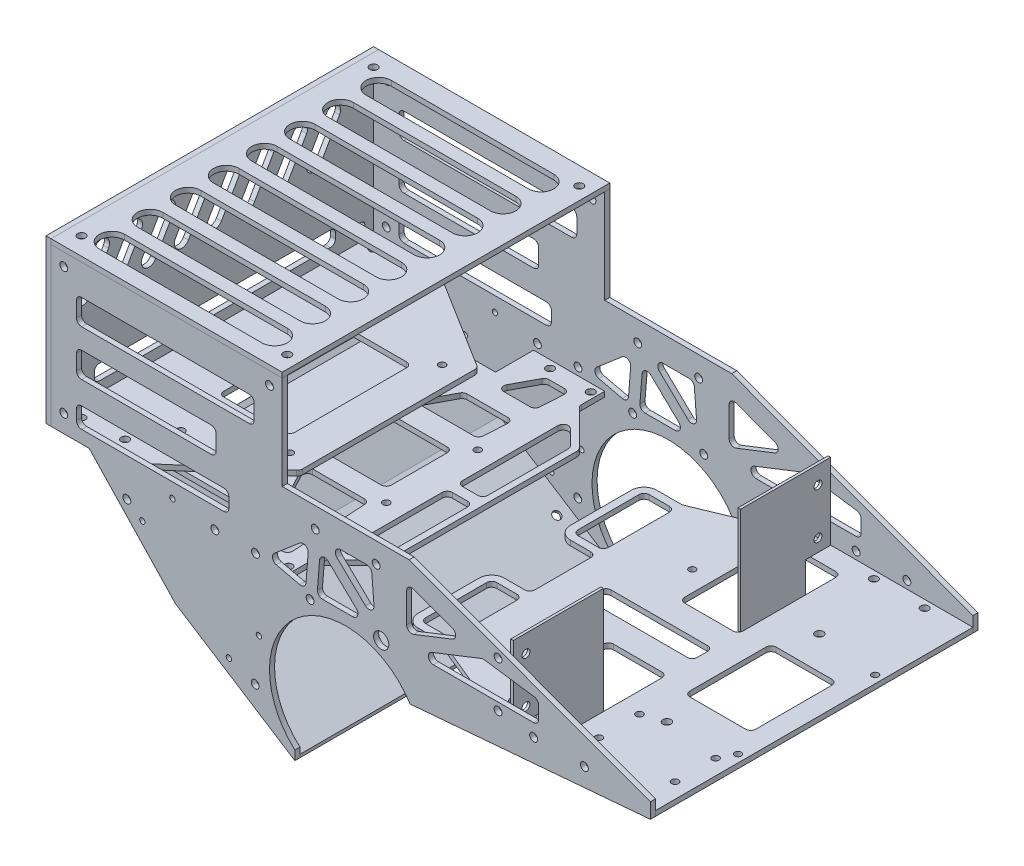
from build123d import *
from build123d.topology import SkipClean

# Parameters (mm, degrees)
SKETCH_1_R                = 1.55
EXTRUDE_1_DEPTH           = 2
SKETCH_2_R                = 1.3
SKETCH_2_R_2              = 1.35
SKETCH_2_R_3              = 1.6
SKETCH_2_W                = 42
SKETCH_2_H                = 8
EXTRUDE_2_DEPTH           = 2
EXTRUDE_START             = -125
SKETCH_1_2_R              = 1.55
EXTRUDE_3_DEPTH           = 2
EXTRUDE_START_2           = -25
SKETCH_16_R               = 1.35
SKETCH_16_R_2             = 1.55
SKETCH_16_W               = 28
SKETCH_16_H               = 48
EXTRUDE_13_DEPTH          = 2
EXTRUDE_START_3           = -10
SKETCH_17_R               = 1.35
SKETCH_17_R_2             = 1.55
SKETCH_17_W               = 26
SKETCH_17_H               = 26
EXTRUDE_14_DEPTH          = 2
SKETCH_47_W               = 10
SKETCH_47_H               = 4
EXTRUDE_27_DEPTH          = 2
EXTRUDE_15_DEPTH          = 2
EXTRUDE_16_DEPTH          = 125
EXTRUDE_16_2_DEPTH        = 125
SKETCH_38_R               = 1.55
CUT_EXTRUDE_12_DEPTH      = 2
SKETCH_31_R               = 1.55
CUT_EXTRUDE_7_DEPTH       = 2
SKETCH_62_R               = 1.55
CUT_EXTRUDE_28_DEPTH      = 228.682265925
SKETCH_39_R               = 1.55
CUT_EXTRUDE_13_DEPTH      = 204.580450928
CUT_EXTRUDE_15_DEPTH      = 203.31905496
CUT_EXTRUDE_15_DEPTH_BACK = 203.31905496
SKETCH_48_W               = 23
SKETCH_48_H               = 40.5
SKETCH_48_W_2             = 26
SKETCH_48_H_2             = 34
CUT_EXTRUDE_19_DEPTH      = 10
FILLET_3_R                = 2
FILLET_6_R                = 2
EXTRUDE_START_4           = -127
EXTRUDE_29_DEPTH          = 2
SKETCH_51_W               = 91
SKETCH_51_H               = 129
EXTRUDE_30_DEPTH          = 2
SKETCH_52_W               = 129
SKETCH_52_H               = 64
EXTRUDE_31_DEPTH          = 2
SKETCH_53_R               = 1.05
SKETCH_53_R_2             = 1.55
CUT_EXTRUDE_20_DEPTH      = 204.334699449
CUT_EXTRUDE_20_DEPTH_BACK = 204.334699449
FILLET_7_R                = 2
SKETCH_55_R               = 1.55
SKETCH_55_W               = 70
SKETCH_55_H               = 10
SKETCH_55_W_2             = 55
SKETCH_55_W_3             = 60
SKETCH_55_H_2             = 8
CUT_EXTRUDE_21_DEPTH      = 205.58983357
SKETCH_56_R               = 1.55
CUT_EXTRUDE_22_DEPTH      = 10
SKETCH_57_R               = 1.55
SKETCH_57_W               = 95
SKETCH_57_H               = 6
CUT_EXTRUDE_23_DEPTH      = 10
EXTRUDE_START_5           = 63
SKETCH_58_W               = 125
SKETCH_58_H               = 42
EXTRUDE_32_DEPTH          = 1
SKETCH_59_R               = 1.55
SKETCH_59_W               = 10
SKETCH_59_H               = 12
SKETCH_59_W_2             = 54
SKETCH_59_H_2             = 50
CUT_EXTRUDE_24_DEPTH      = 2
FILLET_8_R                = 2
FILLET_9_R                = 2
FILLET_10_R               = 2
SKETCH_60_R               = 1.55
CUT_EXTRUDE_26_DEPTH      = 204.334699449
FILLET_11_R               = 2
FILLET_12_R               = 2
SKETCH_61_R               = 3
CUT_EXTRUDE_27_DEPTH      = 2
SKETCH_64_R               = 1.55
CUT_EXTRUDE_29_DEPTH      = 10
SKETCH_65_R               = 1.55
CUT_EXTRUDE_30_DEPTH      = 10


with BuildPart() as part:
    # Sketch 1 → Extrude 1 (new body)
    with BuildSketch(Plane.XY):
        with BuildLine():
            Line((-45, 65), (25, 65))
            Line((25, 65), (120, 30))
            Line((120, 30), (120, 24))
            Line((120, 24), (25.377155081, 16))
            ThreePointArc((25.377155081, 16), (5.441103222, 29.502447284), (-18, 24))
            Line((-18, 24), (-45, 24))
            Line((-45, 24), (-45, 65))
        make_face()
        with Locations((-12, 57)):
            Circle(SKETCH_1_R, mode=Mode.SUBTRACT)
        with Locations((12, 57)):
            Circle(SKETCH_1_R, mode=Mode.SUBTRACT)
        with Locations((60, 49)):
            Circle(SKETCH_1_R, mode=Mode.SUBTRACT)
        with Locations((14, 32)):
            Circle(SKETCH_1_R, mode=Mode.SUBTRACT)
        with Locations((-14, 32)):
            Circle(SKETCH_1_R, mode=Mode.SUBTRACT)
        with Locations((60, 31)):
            Circle(SKETCH_1_R, mode=Mode.SUBTRACT)
    extrude(amount=EXTRUDE_1_DEPTH)


with BuildPart() as body_2:
    # Sketch 2 → Extrude 2 (new body)
    with BuildSketch(Plane(origin=(0, 24, 0), x_dir=(1, 0, 0), z_dir=(0, 1, 0))):
        with BuildLine():
            Line((120, 0), (120, 125))
            Line((120, 125), (21, 125))
            Line((21, 125), (21, 109.5))
            Line((21, 109.5), (11, 109.5))
            ThreePointArc((11, 109.5), (7.464466094, 108.035533906), (6, 104.5))
            Line((6, 104.5), (6, 80.5))
            ThreePointArc((6, 80.5), (7.464466094, 76.964466094), (11, 75.5))
            Line((11, 75.5), (21, 75.5))
            Line((21, 75.5), (21, 49.5))
            Line((21, 49.5), (11, 49.5))
            ThreePointArc((11, 49.5), (7.464466094, 48.035533906), (6, 44.5))
            Line((6, 44.5), (6, 20.5))
            ThreePointArc((6, 20.5), (7.464466094, 16.964466094), (11, 15.5))
            Line((11, 15.5), (21, 15.5))
            Line((21, 15.5), (21, 0))
            Line((21, 0), (120, 0))
        make_face()
        with Locations(Location((117, 89.5, 0), (0, 0, 180))):
            Circle(SKETCH_2_R, mode=Mode.SUBTRACT)
        with Locations(Location((117, 35.5, 0), (0, 0, 180))):
            Circle(SKETCH_2_R, mode=Mode.SUBTRACT)
        with Locations(Location((45, 35.5, 0), (0, 0, 180))):
            Circle(SKETCH_2_R, mode=Mode.SUBTRACT)
        with Locations(Location((45, 89.5, 0), (0, 0, 180))):
            Circle(SKETCH_2_R, mode=Mode.SUBTRACT)
        with Locations(Location((84, 13.7, 0), (0, 0, 180))):
            Circle(SKETCH_2_R_2, mode=Mode.SUBTRACT)
        with Locations(Location((84, 29.7, 0), (0, 0, 180))):
            Circle(SKETCH_2_R_2, mode=Mode.SUBTRACT)
        with Locations(Location((114, 13.7, 0), (0, 0, 180))):
            Circle(SKETCH_2_R_2, mode=Mode.SUBTRACT)
        with Locations(Location((114, 29.7, 0), (0, 0, 180))):
            Circle(SKETCH_2_R_2, mode=Mode.SUBTRACT)
        with Locations(Location((92, 92.5, 0), (0, 0, 180))):
            Circle(SKETCH_2_R_3, mode=Mode.SUBTRACT)
        with Locations(Location((92, 32.5, 0), (0, 0, 180))):
            Circle(SKETCH_2_R_3, mode=Mode.SUBTRACT)
        with Locations(Location((60, 5, 0), (0, 0, 180))):
            Circle(SKETCH_2_R_3, mode=Mode.SUBTRACT)
        with Locations((60, 120)):
            Circle(SKETCH_2_R_3, mode=Mode.SUBTRACT)
        with BuildLine():
            Line((21, 106.5), (11, 106.5))
            ThreePointArc((11, 106.5), (9.585786438, 105.914213562), (9, 104.5))
            Line((9, 104.5), (9, 80.5))
            ThreePointArc((9, 80.5), (9.585786438, 79.085786438), (11, 78.5))
            Line((11, 78.5), (21, 78.5))
            Line((21, 78.5), (21, 106.5))
        make_face(mode=Mode.SUBTRACT)
        with BuildLine():
            Line((21, 46.5), (21, 18.5))
            Line((21, 18.5), (11, 18.5))
            ThreePointArc((11, 18.5), (9.585786438, 19.085786438), (9, 20.5))
            Line((9, 20.5), (9, 44.5))
            ThreePointArc((9, 44.5), (9.585786438, 45.914213562), (11, 46.5))
            Line((11, 46.5), (21, 46.5))
        make_face(mode=Mode.SUBTRACT)
        with Locations((55, 62.5)):
            Rectangle(SKETCH_2_W, SKETCH_2_H, mode=Mode.SUBTRACT)
    extrude(amount=EXTRUDE_2_DEPTH)

    # Sketch 38 → Cut-Extrude 12 (cut)
    with BuildSketch(Plane.XZ.offset(-24)):
        with Locations((104, -3)):
            Circle(SKETCH_38_R)
        with Locations((84, -3)):
            Circle(SKETCH_38_R)
        with Locations((84, -122)):
            Circle(SKETCH_38_R)
        with Locations((104, -122)):
            Circle(SKETCH_38_R)
    extrude(amount=-CUT_EXTRUDE_12_DEPTH, mode=Mode.SUBTRACT)

    # Sketch 48 → Cut-Extrude 19 (cut)
    with BuildSketch(Plane.XZ.offset(-24)):
        with Locations((64.5, -96.75)):
            Rectangle(SKETCH_48_W, SKETCH_48_H)
        with Locations((64.5, -28.25)):
            Rectangle(SKETCH_48_W, SKETCH_48_H)
        Polygon((21, -125), (21, -109.5), (58.45, -125), align=None)
        Polygon((21, -15.5), (21, 0), (58.45, 0), align=None)
        with Locations((99, -62.5)):
            Rectangle(SKETCH_48_W_2, SKETCH_48_H_2)
    extrude(amount=-CUT_EXTRUDE_19_DEPTH, mode=Mode.SUBTRACT)

    # Fillet 3
    fillet_3_edges = [body_2.edges().sort_by_distance(p)[0] for p in [
        (21, 25, -18.5),
        (21, 25, -46.5),
        (53, 25, -48.5),
        (53, 25, -8),
        (76, 25, -8),
        (76, 25, -48.5),
        (86, 25, -79.5),
        (86, 25, -45.5),
        (112, 25, -45.5),
        (112, 25, -79.5),
        (53, 25, -117),
        (53, 25, -76.5),
        (76, 25, -76.5),
        (76, 25, -117),
        (21, 25, -15.5),
        (21, 25, -49.5),
        (21, 25, -75.5),
        (21, 25, -109.5),
        (21, 25, -78.5),
        (21, 25, -106.5),
        (34, 25, -66.5),
        (34, 25, -58.5),
        (76, 25, -58.5),
        (76, 25, -66.5),
    ]]
    fillet(fillet_3_edges, radius=FILLET_3_R)


with BuildPart() as body_3:
    # Sketch 1_2 → Extrude 3 (new body)
    with BuildSketch(Plane.XY.offset(EXTRUDE_START)):
        with BuildLine():
            Line((-45, 65), (25, 65))
            Line((25, 65), (120, 30))
            Line((120, 30), (120, 24))
            Line((120, 24), (25.377155081, 16))
            ThreePointArc((25.377155081, 16), (5.441103222, 29.502447284), (-18, 24))
            Line((-18, 24), (-45, 24))
            Line((-45, 24), (-45, 65))
        make_face()
        with Locations((-12, 57)):
            Circle(SKETCH_1_2_R, mode=Mode.SUBTRACT)
        with Locations((12, 57)):
            Circle(SKETCH_1_2_R, mode=Mode.SUBTRACT)
        with Locations((60, 49)):
            Circle(SKETCH_1_2_R, mode=Mode.SUBTRACT)
        with Locations((14, 32)):
            Circle(SKETCH_1_2_R, mode=Mode.SUBTRACT)
        with Locations((-14, 32)):
            Circle(SKETCH_1_2_R, mode=Mode.SUBTRACT)
        with Locations((60, 31)):
            Circle(SKETCH_1_2_R, mode=Mode.SUBTRACT)
    extrude(amount=-EXTRUDE_3_DEPTH)

    # Sketch 18 → Extrude 15 (add)
    with SkipClean():  # the faces are left unmerged after this step: merging them gives an invalid solid
        with BuildSketch(Plane(origin=(0, 0, -127), x_dir=(-1, 0, 0), z_dir=(0, 0, -1))):
            with BuildLine():
                Line((101, 40), (67, 4))
                Line((67, 4), (20, -26))
                Line((20, -26), (20, -22.360679775))
                ThreePointArc((20, -22.360679775), (29.972123003, 1.292997564), (18, 24))
                Line((18, 24), (45, 24))
                Line((45, 24), (45, 40))
                Line((45, 40), (45, 65))
                Line((45, 65), (25, 65))
                Line((25, 65), (25, 102))
                Line((25, 102), (116, 102))
                Line((116, 102), (116, 40))
                Line((116, 40), (101, 40))
            make_face()
        extrude(amount=-EXTRUDE_15_DEPTH)

    # Sketch 31 → Cut-Extrude 7 (cut)
    with SkipClean():  # the faces are left unmerged after this step: merging them gives an invalid solid
        with BuildSketch(Plane(origin=(0, 0, -127), x_dir=(-1, 0, 0), z_dir=(0, 0, -1))):
            with Locations((35.62096265, -7.724729116)):
                Circle(SKETCH_31_R)
            with Locations((86.148733825, 30.100738593)):
                Circle(SKETCH_31_R)
        extrude(amount=-CUT_EXTRUDE_7_DEPTH, mode=Mode.SUBTRACT)


with BuildPart() as body_4:
    # Sketch 16 → Extrude 13 (new body)
    with BuildSketch(Plane(origin=(0, 65, 0), x_dir=(1, 0, 0), z_dir=(0, 1, 0)).offset(EXTRUDE_START_2)):
        Polygon((-50, 30), (-85, 0), (-116, 0), (-116, 125), (-90, 125), (-50, 100), align=None)
        with Locations(Location((-98, 34, 0), (0, 0, 270))):
            Circle(SKETCH_16_R, mode=Mode.SUBTRACT)
        with Locations(Location((-58, 34, 0), (0, 0, 270))):
            Circle(SKETCH_16_R, mode=Mode.SUBTRACT)
        with Locations(Location((-58, 94, 0), (0, 0, 270))):
            Circle(SKETCH_16_R, mode=Mode.SUBTRACT)
        with Locations(Location((-98, 94, 0), (0, 0, 270))):
            Circle(SKETCH_16_R, mode=Mode.SUBTRACT)
        with Locations(Location((-111, 120, 0), (0, 0, 270))):
            Circle(SKETCH_16_R_2, mode=Mode.SUBTRACT)
        with Locations(Location((-111, 5, 0), (0, 0, 270))):
            Circle(SKETCH_16_R_2, mode=Mode.SUBTRACT)
        with Locations((-78, 64)):
            Rectangle(SKETCH_16_W, SKETCH_16_H, mode=Mode.SUBTRACT)
    extrude(amount=EXTRUDE_13_DEPTH)


with BuildPart() as body_5:
    # Sketch 17 → Extrude 14 (new body)
    with BuildSketch(Plane.XZ.offset(-24).offset(EXTRUDE_START_3)):
        Polygon((-25, -125), (-53, -125), (-53, -110), (-90, -110), (-90, -15), (-53, -15), (-53, 0), (-25, 0), align=None)
        with Locations((-66, -80)):
            Circle(SKETCH_17_R, mode=Mode.SUBTRACT)
        with Locations((-30, -80)):
            Circle(SKETCH_17_R, mode=Mode.SUBTRACT)
        with Locations((-30, -44)):
            Circle(SKETCH_17_R, mode=Mode.SUBTRACT)
        with Locations((-66, -44)):
            Circle(SKETCH_17_R, mode=Mode.SUBTRACT)
        with Locations((-27.5, -3)):
            Circle(SKETCH_17_R_2, mode=Mode.SUBTRACT)
        with Locations((-43.5, -3)):
            Circle(SKETCH_17_R_2, mode=Mode.SUBTRACT)
        with Locations(Location((-27.5, -122, 0), (0, 0, 180))):
            Circle(SKETCH_17_R_2, mode=Mode.SUBTRACT)
        with Locations(Location((-43.5, -122, 0), (0, 0, 180))):
            Circle(SKETCH_17_R_2, mode=Mode.SUBTRACT)
        with Locations((-48, -62)):
            Rectangle(SKETCH_17_W, SKETCH_17_H, mode=Mode.SUBTRACT)
        Polygon((-41.105034236, -118), (-48.06931995, -105), (-32.518984664, -105), (-31.74517514, -118), align=None, mode=Mode.SUBTRACT)
        Polygon((-52.355034236, -97), (-59.31931995, -84), (-33.768984664, -84), (-32.99517514, -97), align=None, mode=Mode.SUBTRACT)
        Polygon((-52.355034236, -28), (-32.99517514, -28), (-33.768984664, -41), (-59.31931995, -41), align=None, mode=Mode.SUBTRACT)
        Polygon((-41.105034236, -7), (-31.74517514, -7), (-32.518984664, -20), (-48.06931995, -20), align=None, mode=Mode.SUBTRACT)
    extrude(amount=EXTRUDE_14_DEPTH)

    # Sketch 47 → Extrude 27 (add)
    with BuildSketch(Plane(origin=(0, 34, 0), x_dir=(1, 0, 0), z_dir=(0, 1, 0))):
        Polygon((-10, 100), (-25, 115), (-25, 10), (-10, 25), align=None)
        Polygon((-22.5, 64.5), (-22.5, 108.964466094), (-12.5, 98.964466094), (-12.5, 64.5), (-12.5, 60.5), (-12.5, 26.035533906), (-22.5, 16.035533906), (-22.5, 60.5), align=None, mode=Mode.SUBTRACT)
        with Locations((-17.5, 62.5)):
            Rectangle(SKETCH_47_W, SKETCH_47_H)
    extrude(amount=-EXTRUDE_27_DEPTH)

    # Fillet 6
    fillet_6_edges = [body_5.edges().sort_by_distance(p)[0] for p in [
        (-25, 33, -10),
        (-25, 33, -115),
        (-12.5, 33, -64.5),
        (-12.5, 33, -98.964466094),
        (-22.5, 33, -108.964466094),
        (-12.5, 33, -60.5),
        (-22.5, 33, -60.5),
        (-22.5, 33, -16.035533906),
        (-22.5, 33, -64.5),
        (-12.5, 33, -26.035533906),
    ]]
    fillet(fillet_6_edges, radius=FILLET_6_R)

    # Fillet 7
    fillet_7_edges = [body_5.edges().sort_by_distance(p)[0] for p in [
        (-10, 33, -25),
        (-10, 33, -100),
    ]]
    fillet(fillet_7_edges, radius=FILLET_7_R)


with BuildPart() as body_6:
    # Sketch 19 → Extrude 16 (new body)
    with BuildSketch(Plane.XY.offset(-125)):
        Polygon((-66.895855681, 3.933524903), (-20, -26), (-20, -24.813650906), (-66.357820228, 4.776447112), align=None)
    extrude(amount=EXTRUDE_16_DEPTH)

    # Sketch 62 → Cut-Extrude 28 (cut, through all)
    with BuildSketch(Plane(origin=(-17.581215825, -27.543904793, 0), x_dir=(0.8429222095775879, -0.5380354529218656, 0), z_dir=(-0.5380354529218656, -0.8429222095775879, 0))):
        with Locations((-25.869522416, -120)):
            Circle(SKETCH_62_R)
        with Locations((-25.869522416, -5)):
            Circle(SKETCH_62_R)
    extrude(amount=-CUT_EXTRUDE_28_DEPTH, mode=Mode.SUBTRACT)

    # Sketch 65 → Cut-Extrude 30 (cut)
    with BuildSketch(Plane(origin=(-17.581215825, -27.543904793, 0), x_dir=(0.8429222095775879, -0.5380354529218656, 0), z_dir=(-0.5380354529218656, -0.8429222095775879, 0))):
        with Locations((-53.504378335, -72.5)):
            Circle(SKETCH_65_R)
        with Locations((-53.504378335, -52.5)):
            Circle(SKETCH_65_R)
    extrude(amount=-CUT_EXTRUDE_30_DEPTH, mode=Mode.SUBTRACT)


with BuildPart() as body_7:
    # Sketch 19 → Extrude 16 2 (new body)
    with BuildSketch(Plane.XY.offset(-125)):
        Polygon((-67.08483338, 4.089823579), (-66.357820228, 4.776447112), (-93.406751518, 33.416492007), (-94.13376467, 32.729868475), align=None)
    extrude(amount=EXTRUDE_16_2_DEPTH)

    # Sketch 64 → Cut-Extrude 29 (cut)
    with BuildSketch(Plane(origin=(-33.415986949, -31.55954323, 0), x_dir=(0, 0, 1), z_dir=(-0.7270131525498174, -0.6866235329637167, 0))):
        with Locations(Location((-72.5, 54.035380838, 0), (0, 0, 270))):
            Circle(SKETCH_64_R)
        with Locations(Location((-52.5, 54.035380838, 0), (0, 0, 270))):
            Circle(SKETCH_64_R)
        with Locations(Location((-120, 81.035380838, 0), (0, 0, 270))):
            Circle(SKETCH_64_R)
        with Locations(Location((-5, 81.035380838, 0), (0, 0, 270))):
            Circle(SKETCH_64_R)
    extrude(amount=-CUT_EXTRUDE_29_DEPTH, mode=Mode.SUBTRACT)


with BuildPart() as cut_extrude_13_tool:
    # Sketch 39 → Cut-Extrude 13 (new, through all)
    with SkipClean():  # the faces are left unmerged after this step: merging them gives an invalid solid
        with BuildSketch(Plane(origin=(0, 0, -127), x_dir=(-1, 0, 0), z_dir=(0, 0, -1))):
            with Locations((-74, 29)):
                Circle(SKETCH_39_R)
            with Locations((-94, 29)):
                Circle(SKETCH_39_R)
        extrude(amount=-CUT_EXTRUDE_13_DEPTH)


with BuildPart() as part_1:
    with SkipClean():  # the faces are left unmerged after this step: merging them gives an invalid solid
        add(part.part)

        # Cut-Extrude 13: cut by cut_extrude_13_tool
        add(cut_extrude_13_tool.part, mode=Mode.SUBTRACT)


with BuildPart() as body_3_1:
    with SkipClean():  # the faces are left unmerged after this step: merging them gives an invalid solid
        add(body_3.part)

        # Cut-Extrude 13: cut by cut_extrude_13_tool
        add(cut_extrude_13_tool.part, mode=Mode.SUBTRACT)


with BuildPart() as cut_extrude_15_tool:
    # Sketch 41 → Cut-Extrude 15 (new, two sides)
    with SkipClean():  # the faces are left unmerged after this step: merging them gives an invalid solid
        with BuildSketch(Plane(origin=(0, 0, 0), x_dir=(-1, 0, 0), z_dir=(0, 0, -1))) as cut_extrude_15_sk:
            Polygon((-24, 56.84275506), (-24, 39.372271948), (-46.94445184, 48.389535961), align=None)
            Polygon((-24, 34), (-76, 34), (-76, 37.684860324), (-76, 42.684860324), (-54, 45.790123482), align=None)
        extrude(amount=CUT_EXTRUDE_15_DEPTH)
        extrude(cut_extrude_15_sk.sketch, amount=-CUT_EXTRUDE_15_DEPTH_BACK)


with BuildPart() as part_2:
    with SkipClean():  # the faces are left unmerged after this step: merging them gives an invalid solid
        add(part_1.part)

        # Cut-Extrude 15: cut by cut_extrude_15_tool
        add(cut_extrude_15_tool.part, mode=Mode.SUBTRACT)

    # Sketch 18_2 → Extrude 29 (add)
    with BuildSketch(Plane(origin=(0, 0, -127), x_dir=(-1, 0, 0), z_dir=(0, 0, -1)).offset(EXTRUDE_START_4)):
        with BuildLine():
            Line((101, 40), (67, 4))
            Line((67, 4), (20, -26))
            Line((20, -26), (20, -22.360679775))
            ThreePointArc((20, -22.360679775), (29.972123003, 1.292997564), (18, 24))
            Line((18, 24), (45, 24))
            Line((45, 24), (45, 40))
            Line((45, 40), (45, 65))
            Line((45, 65), (25, 65))
            Line((25, 65), (25, 102))
            Line((25, 102), (116, 102))
            Line((116, 102), (116, 40))
            Line((116, 40), (101, 40))
        make_face()
    extrude(amount=-EXTRUDE_29_DEPTH)


with BuildPart() as body_3_2:
    with SkipClean():  # the faces are left unmerged after this step: merging them gives an invalid solid
        add(body_3_1.part)

        # Cut-Extrude 15: cut by cut_extrude_15_tool
        add(cut_extrude_15_tool.part, mode=Mode.SUBTRACT)


with BuildPart() as body_8:
    # Sketch 51 → Extrude 30 (new body)
    with BuildSketch(Plane(origin=(0, 102, 0), x_dir=(1, 0, 0), z_dir=(0, 1, 0))):
        with Locations((-70.5, 62.5)):
            Rectangle(SKETCH_51_W, SKETCH_51_H)
    extrude(amount=EXTRUDE_30_DEPTH)

    # Sketch 56 → Cut-Extrude 22 (cut)
    with BuildSketch(Plane(origin=(0, 104, 0), x_dir=(1, 0, 0), z_dir=(0, 1, 0))):
        with Locations(Location((-30, 5, 0), (0, 0, 270))):
            Circle(SKETCH_56_R)
        with Locations(Location((-30, 120, 0), (0, 0, 270))):
            Circle(SKETCH_56_R)
        with Locations(Location((-111, 5, 0), (0, 0, 270))):
            Circle(SKETCH_56_R)
        with Locations(Location((-111, 120, 0), (0, 0, 270))):
            Circle(SKETCH_56_R)
        with BuildLine():
            Line((-39, 109), (-103, 109))
            ThreePointArc((-103, 109), (-108, 114), (-103, 119))
            Line((-103, 119), (-39, 119))
            ThreePointArc((-39, 119), (-34, 114), (-39, 109))
        make_face()
        with BuildLine():
            Line((-39, 94), (-103, 94))
            ThreePointArc((-103, 94), (-108, 99), (-103, 104))
            Line((-103, 104), (-39, 104))
            ThreePointArc((-39, 104), (-34, 99), (-39, 94))
        make_face()
        with BuildLine():
            Line((-39, 79), (-103, 79))
            ThreePointArc((-103, 79), (-108, 84), (-103, 89))
            Line((-103, 89), (-39, 89))
            ThreePointArc((-39, 89), (-34, 84), (-39, 79))
        make_face()
        with BuildLine():
            Line((-39, 64), (-103, 64))
            ThreePointArc((-103, 64), (-108, 69), (-103, 74))
            Line((-103, 74), (-39, 74))
            ThreePointArc((-39, 74), (-34, 69), (-39, 64))
        make_face()
        with BuildLine():
            Line((-39, 49), (-103, 49))
            ThreePointArc((-103, 49), (-108, 54), (-103, 59))
            Line((-103, 59), (-39, 59))
            ThreePointArc((-39, 59), (-34, 54), (-39, 49))
        make_face()
        with BuildLine():
            Line((-39, 34), (-103, 34))
            ThreePointArc((-103, 34), (-108, 39), (-103, 44))
            Line((-103, 44), (-39, 44))
            ThreePointArc((-39, 44), (-34, 39), (-39, 34))
        make_face()
        with BuildLine():
            Line((-39, 19), (-103, 19))
            ThreePointArc((-103, 19), (-108, 24), (-103, 29))
            Line((-103, 29), (-39, 29))
            ThreePointArc((-39, 29), (-34, 24), (-39, 19))
        make_face()
        with BuildLine():
            Line((-39, 4), (-103, 4))
            ThreePointArc((-103, 4), (-108, 9), (-103, 14))
            Line((-103, 14), (-39, 14))
            ThreePointArc((-39, 14), (-34, 9), (-39, 4))
        make_face()
    extrude(amount=-CUT_EXTRUDE_22_DEPTH, mode=Mode.SUBTRACT)


with BuildPart() as body_9:
    # Sketch 52 → Extrude 31 (new body)
    with BuildSketch(Plane.ZY.offset(116)):
        with Locations((-62.5, 72)):
            Rectangle(SKETCH_52_W, SKETCH_52_H)
    extrude(amount=EXTRUDE_31_DEPTH)

    # Sketch 57 → Cut-Extrude 23 (cut)
    with BuildSketch(Plane.ZY.offset(118)):
        with Locations((-120, 97)):
            Circle(SKETCH_57_R)
        with Locations((-120, 47)):
            Circle(SKETCH_57_R)
        with Locations((-5, 47)):
            Circle(SKETCH_57_R)
        with Locations((-5, 97)):
            Circle(SKETCH_57_R)
        with BuildLine():
            Line((-106.401923789, 92.5), (-98.901923789, 79.509618943))
            ThreePointArc((-98.901923789, 79.509618943), (-100, 75.411542732), (-104.098076211, 76.509618943))
            Line((-104.098076211, 76.509618943), (-111.598076211, 89.5))
            ThreePointArc((-111.598076211, 89.5), (-110.5, 93.598076211), (-106.401923789, 92.5))
        make_face()
        with Locations((-62.5, 49)):
            Rectangle(SKETCH_57_W, SKETCH_57_H)
        with BuildLine():
            Line((-98.598076211, 89.5), (-91.098076211, 76.509618943))
            ThreePointArc((-91.098076211, 76.509618943), (-87, 75.411542732), (-85.901923789, 79.509618943))
            Line((-85.901923789, 79.509618943), (-93.401923789, 92.5))
            ThreePointArc((-93.401923789, 92.5), (-97.5, 93.598076211), (-98.598076211, 89.5))
        make_face()
        with BuildLine():
            Line((-85.598076211, 89.5), (-78.098076211, 76.509618943))
            ThreePointArc((-78.098076211, 76.509618943), (-74, 75.411542732), (-72.901923789, 79.509618943))
            Line((-72.901923789, 79.509618943), (-80.401923789, 92.5))
            ThreePointArc((-80.401923789, 92.5), (-84.5, 93.598076211), (-85.598076211, 89.5))
        make_face()
        with BuildLine():
            Line((-72.598076211, 89.5), (-65.098076211, 76.509618943))
            ThreePointArc((-65.098076211, 76.509618943), (-61, 75.411542732), (-59.901923789, 79.509618943))
            Line((-59.901923789, 79.509618943), (-67.401923789, 92.5))
            ThreePointArc((-67.401923789, 92.5), (-71.5, 93.598076211), (-72.598076211, 89.5))
        make_face()
        with BuildLine():
            Line((-59.598076211, 89.5), (-52.098076211, 76.509618943))
            ThreePointArc((-52.098076211, 76.509618943), (-48, 75.411542732), (-46.901923789, 79.509618943))
            Line((-46.901923789, 79.509618943), (-54.401923789, 92.5))
            ThreePointArc((-54.401923789, 92.5), (-58.5, 93.598076211), (-59.598076211, 89.5))
        make_face()
        with BuildLine():
            Line((-46.598076211, 89.5), (-39.098076211, 76.509618943))
            ThreePointArc((-39.098076211, 76.509618943), (-35, 75.411542732), (-33.901923789, 79.509618943))
            Line((-33.901923789, 79.509618943), (-41.401923789, 92.5))
            ThreePointArc((-41.401923789, 92.5), (-45.5, 93.598076211), (-46.598076211, 89.5))
        make_face()
        with BuildLine():
            Line((-33.598076211, 89.5), (-26.098076211, 76.509618943))
            ThreePointArc((-26.098076211, 76.509618943), (-22, 75.411542732), (-20.901923789, 79.509618943))
            Line((-20.901923789, 79.509618943), (-28.401923789, 92.5))
            ThreePointArc((-28.401923789, 92.5), (-32.5, 93.598076211), (-33.598076211, 89.5))
        make_face()
        with BuildLine():
            Line((-20.598076211, 89.5), (-13.098076211, 76.509618943))
            ThreePointArc((-13.098076211, 76.509618943), (-9, 75.411542732), (-7.901923789, 79.509618943))
            Line((-7.901923789, 79.509618943), (-15.401923789, 92.5))
            ThreePointArc((-15.401923789, 92.5), (-19.5, 93.598076211), (-20.598076211, 89.5))
        make_face()
    extrude(amount=-CUT_EXTRUDE_23_DEPTH, mode=Mode.SUBTRACT)

    # Fillet 10
    fillet_10_edges = [body_9.edges().sort_by_distance(p)[0] for p in [
        (-117, 46, -110),
        (-117, 52, -110),
        (-117, 52, -15),
        (-117, 46, -15),
    ]]
    fillet(fillet_10_edges, radius=FILLET_10_R)


with BuildPart() as cut_extrude_20_tool:
    # Sketch 53 → Cut-Extrude 20 (new, two sides)
    with SkipClean():  # the faces are left unmerged after this step: merging them gives an invalid solid
        with BuildSketch(Plane.XY) as cut_extrude_20_sk:
            with Locations((-68.225714805, 39.27883549)):
                Circle(SKETCH_53_R)
            with Locations((-80.059282873, 25.715404258)):
                Circle(SKETCH_53_R)
            with Locations((-46, -4)):
                Circle(SKETCH_53_R)
            with Locations((-34.166431933, 9.563431232)):
                Circle(SKETCH_53_R)
            with Locations(Location((-86.148733825, 30.100738593, 0), (0, 0, 180))):
                Circle(SKETCH_53_R_2)
            with Locations(Location((-35.62096265, -7.724729116, 0), (0, 0, 180))):
                Circle(SKETCH_53_R_2)
        extrude(amount=CUT_EXTRUDE_20_DEPTH)
        extrude(cut_extrude_20_sk.sketch, amount=-CUT_EXTRUDE_20_DEPTH_BACK)


with BuildPart() as body_3_3:
    with SkipClean():  # the faces are left unmerged after this step: merging them gives an invalid solid
        add(body_3_2.part)

        # Cut-Extrude 20: cut by cut_extrude_20_tool
        add(cut_extrude_20_tool.part, mode=Mode.SUBTRACT)


with BuildPart() as part_3:
    with SkipClean():  # the faces are left unmerged after this step: merging them gives an invalid solid
        add(part_2.part)

        # Cut-Extrude 20: cut by cut_extrude_20_tool
        add(cut_extrude_20_tool.part, mode=Mode.SUBTRACT)


with BuildPart() as cut_extrude_21_tool:
    # Sketch 55 → Cut-Extrude 21 (new, through all)
    with SkipClean():  # the faces are left unmerged after this step: merging them gives an invalid solid
        with BuildSketch(Plane.XY.offset(2)):
            with Locations((-111, 97)):
                Circle(SKETCH_55_R)
            with Locations((-111, 47)):
                Circle(SKETCH_55_R)
            with Locations((-30, 97)):
                Circle(SKETCH_55_R)
            with Locations((-35.5, 37)):
                Circle(SKETCH_55_R)
            with Locations((-51.5, 37)):
                Circle(SKETCH_55_R)
            with Locations((-71, 85)):
                Rectangle(SKETCH_55_W, SKETCH_55_H)
            with Locations((-78.5, 67)):
                Rectangle(SKETCH_55_W_2, SKETCH_55_H)
            with Locations((-76, 49)):
                Rectangle(SKETCH_55_W_3, SKETCH_55_H_2)
            Polygon((7.793062241, 34.5), (-9.928793116, 51.540245536), (-11.292012759, 34.5), align=None)
            Polygon((10.153610207, 55), (-7.034449793, 55), (11.585948541, 37.095770833), align=None)
            Polygon((-31.181491585, 38.049066885), (-14.378425929, 52.349548295), (-15.80847407, 34.473946533), align=None)
        extrude(amount=-CUT_EXTRUDE_21_DEPTH)


with BuildPart() as part_4:
    with SkipClean():  # the faces are left unmerged after this step: merging them gives an invalid solid
        add(part_3.part)

        # Cut-Extrude 21: cut by cut_extrude_21_tool
        add(cut_extrude_21_tool.part, mode=Mode.SUBTRACT)

    # Fillet 9
    fillet_9_edges = [part_4.edges().sort_by_distance(p)[0] for p in [
        (-106, 80, 1),
        (-106, 90, 1),
        (-36, 90, 1),
        (-36, 80, 1),
        (-106, 62, 1),
        (-106, 72, 1),
        (-51, 72, 1),
        (-51, 62, 1),
        (-106, 45, 1),
        (-106, 53, 1),
        (-46, 53, 1),
        (-46, 45, 1),
        (7.793062241, 34.5, 1),
        (-11.292012759, 34.5, 1),
        (-9.928793116, 51.540245536, 1),
        (10.153610207, 55, 1),
        (11.585948541, 37.095770833, 1),
        (-7.034449793, 55, 1),
        (-15.80847407, 34.473946533, 1),
        (-31.181491585, 38.049066885, 1),
        (-14.378425929, 52.349548295, 1),
        (46.94445184, 48.389535961, 1),
        (24, 56.84275506, 1),
        (24, 39.372271948, 1),
        (54, 45.790123482, 1),
        (24, 34, 1),
        (76, 34, 1),
        (76, 42.684860324, 1),
    ]]
    fillet(fillet_9_edges, radius=FILLET_9_R)

    # Sketch 61 → Cut-Extrude 27 (cut)
    with BuildSketch(Plane.XY.offset(2)):
        with Locations((14, 32)):
            Circle(SKETCH_61_R)
    extrude(amount=-CUT_EXTRUDE_27_DEPTH, mode=Mode.SUBTRACT)


with BuildPart() as body_3_4:
    with SkipClean():  # the faces are left unmerged after this step: merging them gives an invalid solid
        add(body_3_3.part)

        # Cut-Extrude 21: cut by cut_extrude_21_tool
        add(cut_extrude_21_tool.part, mode=Mode.SUBTRACT)

    # Fillet 8
    fillet_8_edges = [body_3_4.edges().sort_by_distance(p)[0] for p in [
        (46.94445184, 48.389535961, -126),
        (24, 56.84275506, -126),
        (24, 39.372271948, -126),
        (54, 45.790123482, -126),
        (24, 34, -126),
        (76, 34, -126),
        (76, 42.684860324, -126),
        (-106, 80, -126),
        (-106, 90, -126),
        (-36, 90, -126),
        (-36, 80, -126),
        (-106, 62, -126),
        (-106, 72, -126),
        (-51, 72, -126),
        (-51, 62, -126),
        (-106, 45, -126),
        (-106, 53, -126),
        (-46, 53, -126),
        (-46, 45, -126),
        (7.793062241, 34.5, -126),
        (-11.292012759, 34.5, -126),
        (-9.928793116, 51.540245536, -126),
        (10.153610207, 55, -126),
        (11.585948541, 37.095770833, -126),
        (-7.034449793, 55, -126),
        (-15.80847407, 34.473946533, -126),
        (-31.181491585, 38.049066885, -126),
        (-14.378425929, 52.349548295, -126),
    ]]
    fillet(fillet_8_edges, radius=FILLET_8_R)


with BuildPart() as body_10:
    # Sketch 58 → Extrude 32 (new body)
    with BuildSketch(Plane(origin=(0, 0, 0), x_dir=(0, 0, -1), z_dir=(1, 0, 0)).offset(EXTRUDE_START_5)):
        with Locations((62.5, 35)):
            Rectangle(SKETCH_58_W, SKETCH_58_H)
    extrude(amount=EXTRUDE_32_DEPTH)

    # Sketch 59 → Cut-Extrude 24 (cut)
    with BuildSketch(Plane(origin=(64, 0, 0), x_dir=(0, 0, -1), z_dir=(1, 0, 0))):
        with Locations((5, 31)):
            Circle(SKETCH_59_R)
        with Locations((120, 31)):
            Circle(SKETCH_59_R)
        with Locations((5, 49)):
            Circle(SKETCH_59_R)
        with Locations((120, 49)):
            Circle(SKETCH_59_R)
        with Locations((5, 20)):
            Rectangle(SKETCH_59_W, SKETCH_59_H)
        with Locations((62.5, 39)):
            Rectangle(SKETCH_59_W_2, SKETCH_59_H_2)
        with Locations((120, 20)):
            Rectangle(SKETCH_59_W, SKETCH_59_H)
    extrude(amount=-CUT_EXTRUDE_24_DEPTH, mode=Mode.SUBTRACT)


with BuildPart() as cut_extrude_24_piece_1:
    # of the separate pieces the step leaves, piece 1, a body of its own (cut_extrude_24_pieces)
    add(body_10.part.solids().sort_by_distance((63, 56, -89.5))[0])


with BuildPart() as cut_extrude_24_piece_2:
    # of the separate pieces the step leaves, piece 2, a body of its own (cut_extrude_24_pieces)
    add(body_10.part.solids().sort_by_distance((63, 56, 0))[0])


with BuildPart() as cut_extrude_26_tool:
    # Sketch 60 → Cut-Extrude 26 (new, through all)
    with BuildSketch(Plane(origin=(0, 0, 0), x_dir=(1, 0, 0), z_dir=(0, 1, 0))):
        with Locations(Location((-95, 118.856406461, 0), (0, 0, 90))):
            Circle(SKETCH_60_R)
        with Locations(Location((-87, 105, 0), (0, 0, 90))):
            Circle(SKETCH_60_R)
        with Locations(Location((-87, 20, 0), (0, 0, 90))):
            Circle(SKETCH_60_R)
        with Locations(Location((-95, 6.143593539, 0), (0, 0, 90))):
            Circle(SKETCH_60_R)
    extrude(amount=CUT_EXTRUDE_26_DEPTH)


with BuildPart() as body_5_1:
    add(body_5.part)

    # Cut-Extrude 26: cut by cut_extrude_26_tool
    add(cut_extrude_26_tool.part, mode=Mode.SUBTRACT)

    # Fillet 12
    fillet_12_edges = [body_5_1.edges().sort_by_distance(p)[0] for p in [
        (-32.518984664, 33, -20),
        (-31.74517514, 33, -7),
        (-41.105034236, 33, -7),
        (-48.06931995, 33, -20),
        (-61, 33, -49),
        (-61, 33, -75),
        (-35, 33, -75),
        (-35, 33, -49),
        (-41.105034236, 33, -118),
        (-31.74517514, 33, -118),
        (-32.518984664, 33, -105),
        (-48.06931995, 33, -105),
        (-52.355034236, 33, -97),
        (-32.99517514, 33, -97),
        (-33.768984664, 33, -84),
        (-59.31931995, 33, -84),
        (-33.768984664, 33, -41),
        (-32.99517514, 33, -28),
        (-52.355034236, 33, -28),
        (-59.31931995, 33, -41),
    ]]
    fillet(fillet_12_edges, radius=FILLET_12_R)


with BuildPart() as body_4_1:
    add(body_4.part)

    # Cut-Extrude 26: cut by cut_extrude_26_tool
    add(cut_extrude_26_tool.part, mode=Mode.SUBTRACT)

    # Fillet 11
    fillet_11_edges = [body_4_1.edges().sort_by_distance(p)[0] for p in [
        (-116, 41, -125),
        (-90, 41, -125),
        (-50, 41, -100),
        (-50, 41, -30),
        (-85, 41, 0),
        (-116, 41, 0),
        (-64, 41, -88),
        (-92, 41, -88),
        (-92, 41, -40),
        (-64, 41, -40),
    ]]
    fillet(fillet_11_edges, radius=FILLET_11_R)


solid = Compound([body_2.part, body_6.part, body_7.part, body_8.part, body_9.part, part_4.part, body_3_4.part, cut_extrude_24_piece_1.part, cut_extrude_24_piece_2.part, body_5_1.part, body_4_1.part])
